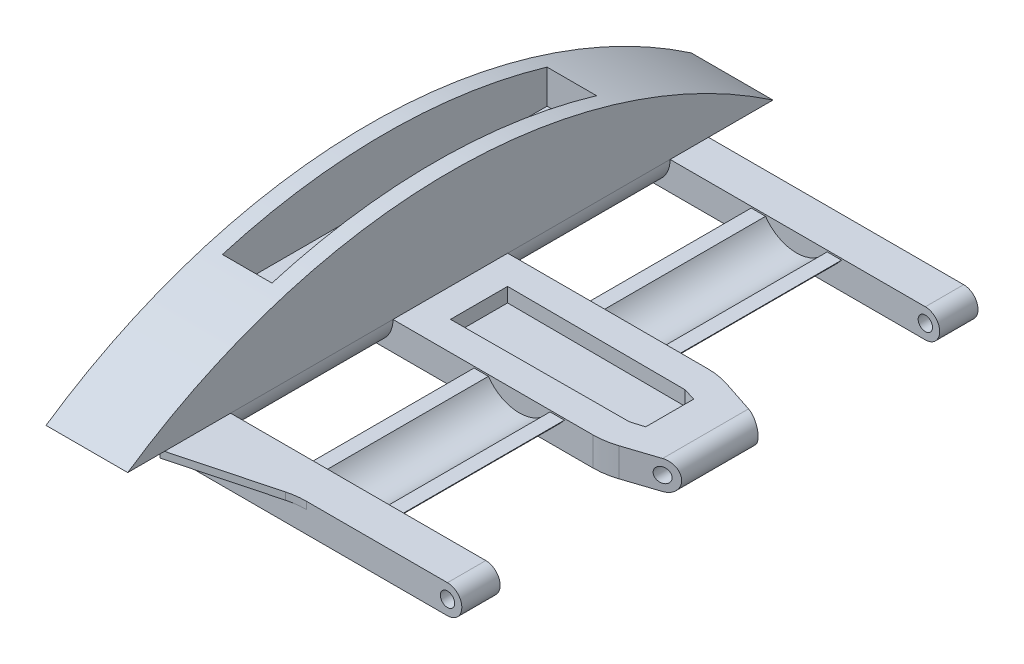
from build123d import *

# Parameters (mm, degrees)
BOSS_EXTRUDE1_DEPTH  = 2.7
SKETCH6_W            = 21.5
SKETCH6_H            = 36
BOSS_EXTRUDE2_DEPTH  = 2
SKETCH7_W            = 18.8
SKETCH7_H            = 11.32703558
CUT_EXTRUDE3_DEPTH   = 2
CUT_EXTRUDE4_DEPTH   = 41.5
SKETCH10_R           = 0.5
CUT_EXTRUDE5_DEPTH   = 41.5
CUT_EXTRUDE15_DEPTH  = 16
FILLET6_R            = 5
BOSS_EXTRUDE6_DEPTH  = 36
CUT_EXTRUDE18_DEPTH  = 1
CUT_EXTRUDE22_DEPTH  = 11.327036
CUT_EXTRUDE23_DEPTH  = 11.327036
BOSS_EXTRUDE10_DEPTH = 3
SKETCH43_W           = 2.3
SKETCH43_H           = 2.67296442
SKETCH43_H_2         = 8
SKETCH45_R           = 0.5
CUT_EXTRUDE26_DEPTH  = 38.82703558
SKETCH47_W           = 3.454078762
SKETCH47_H           = 22.63811533
CUT_EXTRUDE27_DEPTH  = 4
FILLET13_R           = 2
FILLET15_R           = 1
BOSS_EXTRUDE5_DEPTH  = 0.5
FILLET7_R            = 5


with BuildPart() as part:
    # Sketch3 → Boss-Extrude1 (new body)
    with BuildSketch(Plane(origin=(0, 0, 0), x_dir=(0, 0, -1), z_dir=(1, 0, 0))):
        with BuildLine():
            Line((0, 0), (45, 0))
            ThreePointArc((45, 0), (22.5, 6.928108612), (0, 0))
        make_face()
    extrude(amount=BOSS_EXTRUDE1_DEPTH)

    # Sketch6 → Boss-Extrude2 (add)
    with BuildSketch(Plane.XZ):
        with Locations((10.75, -22.5)):
            Rectangle(SKETCH6_W, SKETCH6_H)
    extrude(amount=BOSS_EXTRUDE2_DEPTH)

    # Sketch7 → Cut-Extrude3 (cut)
    with BuildSketch(Plane(origin=(0, 0, 0), x_dir=(1, 0, 0), z_dir=(0, 1, 0))):
        with Locations((12.1, 32.16351779)):
            Rectangle(SKETCH7_W, SKETCH7_H)
        with Locations((12.1, 12.83648221)):
            Rectangle(SKETCH7_W, SKETCH7_H)
    extrude(amount=-CUT_EXTRUDE3_DEPTH, mode=Mode.SUBTRACT)

    # Sketch8 → Cut-Extrude4 (cut, through all)
    with BuildSketch(Plane(origin=(0, 0, -40.5), x_dir=(-1, 0, 0), z_dir=(0, 0, -1))):
        with BuildLine():
            ThreePointArc((-21.5, -1), (-21.207106781, -0.292893219), (-20.5, 0))
            Line((-20.5, 0), (-21.5, 0))
            Line((-21.5, 0), (-21.5, -1))
        make_face()
        with BuildLine():
            ThreePointArc((-20.5, -2), (-21.207106781, -1.707106781), (-21.5, -1))
            Line((-21.5, -1), (-21.5, -2))
            Line((-21.5, -2), (-20.5, -2))
        make_face()
    extrude(amount=-CUT_EXTRUDE4_DEPTH, mode=Mode.SUBTRACT)

    # Sketch10 → Cut-Extrude5 (cut, through all)
    with BuildSketch(Plane(origin=(0, 0, -40.5), x_dir=(-1, 0, 0), z_dir=(0, 0, -1))):
        with Locations((-20.5, -1)):
            Circle(SKETCH10_R)
    extrude(amount=-CUT_EXTRUDE5_DEPTH, mode=Mode.SUBTRACT)

    # Sketch23 → Cut-Extrude15 (cut)
    with BuildSketch(Plane(origin=(0, 0, 0), x_dir=(1, 0, 0), z_dir=(0, 1, 0))):
        Polygon((11.878000054, 16.672665213), (21.5, 19.832983358), (21.5, 13.512347067), align=None)
        Polygon((21.5, 25.167016642), (21.5, 31.487652933), (11.878000054, 28.327334787), align=None)
    extrude(amount=-CUT_EXTRUDE15_DEPTH, mode=Mode.SUBTRACT)

    # Fillet6
    fillet6_edges = [part.edges().sort_by_distance(p)[0] for p in [
        (17.441558662, -1, -26.5),
        (17.441558662, -1, -18.5),
    ]]
    fillet(fillet6_edges, radius=FILLET6_R)

    # Sketch31 → Boss-Extrude6 (add)
    with BuildSketch(Plane(origin=(0, 0, -40.5), x_dir=(-1, 0, 0), z_dir=(0, 0, -1))):
        with BuildLine():
            Line((-14.656442534, -0.106610148), (-8.356442534, -0.106610148))
            ThreePointArc((-8.356442534, -0.106610148), (-11.506442534, -1.641351541), (-14.656442534, -0.106610148))
        make_face()
    extrude(amount=-BOSS_EXTRUDE6_DEPTH)

    # Sketch30 → Cut-Extrude18 (cut)
    with BuildSketch(Plane(origin=(0, 0, 0), x_dir=(1, 0, 0), z_dir=(0, 1, 0))):
        Polygon((17.131265183, 24.438450908), (4.7, 24.491454375), (4.7, 20.508545625), (17.131265183, 20.561549092), (18, 20.824521551), (18, 24.175478449), align=None)
    extrude(amount=-CUT_EXTRUDE18_DEPTH, mode=Mode.SUBTRACT)

    # Sketch36 → Cut-Extrude22 (cut)
    with BuildSketch(Plane.XY.offset(-37.82703558)):
        with BuildLine():
            Line((9.356442534, -0.106610148), (13.656442534, -0.106610148))
            ThreePointArc((13.656442534, -0.106610148), (11.506442534, -1.243174514), (9.356442534, -0.106610148))
        make_face()
    extrude(amount=CUT_EXTRUDE22_DEPTH, mode=Mode.SUBTRACT)

    # Sketch37 → Cut-Extrude23 (cut)
    with BuildSketch(Plane(origin=(0, 0, -7.17296442), x_dir=(-1, 0, 0), z_dir=(0, 0, -1))):
        with BuildLine():
            Line((-13.656442534, -0.106610148), (-9.356442534, -0.106610148))
            ThreePointArc((-9.356442534, -0.106610148), (-11.506442534, -1.243174514), (-13.656442534, -0.106610148))
        make_face()
    extrude(amount=CUT_EXTRUDE23_DEPTH, mode=Mode.SUBTRACT)

    # Sketch42 → Boss-Extrude10 (add)
    with BuildSketch(Plane.ZY):
        with BuildLine():
            Line((-45, 0), (-40.5, 0))
            Line((-40.5, 0), (-40.5, -2))
            Line((-40.5, -2), (-4.5, -2))
            Line((-4.5, -2), (-4.5, 0))
            Line((-4.5, 0), (0, 0))
            ThreePointArc((0, 0), (-22.5, 6.928108612), (-45, 0))
        make_face()
    extrude(amount=BOSS_EXTRUDE10_DEPTH)

    # Sketch43 → Cut-Revolve7 (revolve, cut)
    with BuildSketch(Plane.XZ.offset(2)):
        with Locations((-1.85, -5.83648221)):
            Rectangle(SKETCH43_W, SKETCH43_H)
        with Locations((-1.85, -22.5)):
            Rectangle(SKETCH43_W, SKETCH43_H_2)
        with Locations((-1.85, -39.16351779)):
            Rectangle(SKETCH43_W, SKETCH43_H)
    revolve(axis=Axis((-3, -2, -4.5), (0, 0, -1)), mode=Mode.SUBTRACT)

    # Sketch45 → Cut-Extrude26 (cut, through all)
    with BuildSketch(Plane.XY.offset(-7.17296442)):
        with Locations((-2, -1)):
            Circle(SKETCH45_R)
    extrude(amount=-CUT_EXTRUDE26_DEPTH, mode=Mode.SUBTRACT)

    # Sketch47 → Cut-Extrude27 (cut)
    with BuildSketch(Plane(origin=(0, 6.928108612, 0), x_dir=(1, 0, 0), z_dir=(0, 1, 0))):
        with Locations((-0.15, 22.5)):
            Rectangle(SKETCH47_W, SKETCH47_H)
    extrude(amount=-CUT_EXTRUDE27_DEPTH, mode=Mode.SUBTRACT)

    # Fillet13
    fillet13_edges = [part.edges().sort_by_distance(p)[0] for p in [
        (2.7, -2, -12.83648221),
        (2.7, -2, -32.16351779),
    ]]
    fillet(fillet13_edges, radius=FILLET13_R)

    # Fillet15
    fillet15_edges = [part.edges().sort_by_distance(p)[0] for p in [
        (-3, -2, -32.16351779),
        (-3, -2, -12.83648221),
    ]]
    fillet(fillet15_edges, radius=FILLET15_R)

    # Sketch27 → Boss-Extrude5 (add)
    with BuildSketch(Plane.XZ):
        Polygon((2.45, -4.5), (10, -4.5), (2.45, -2.5), align=None)
    extrude(amount=BOSS_EXTRUDE5_DEPTH)

    # Fillet7
    fillet7_edges = [part.edges().sort_by_distance(p)[0] for p in [
        (10, -0.25, -4.5),
    ]]
    fillet(fillet7_edges, radius=FILLET7_R)


solid = part.part
